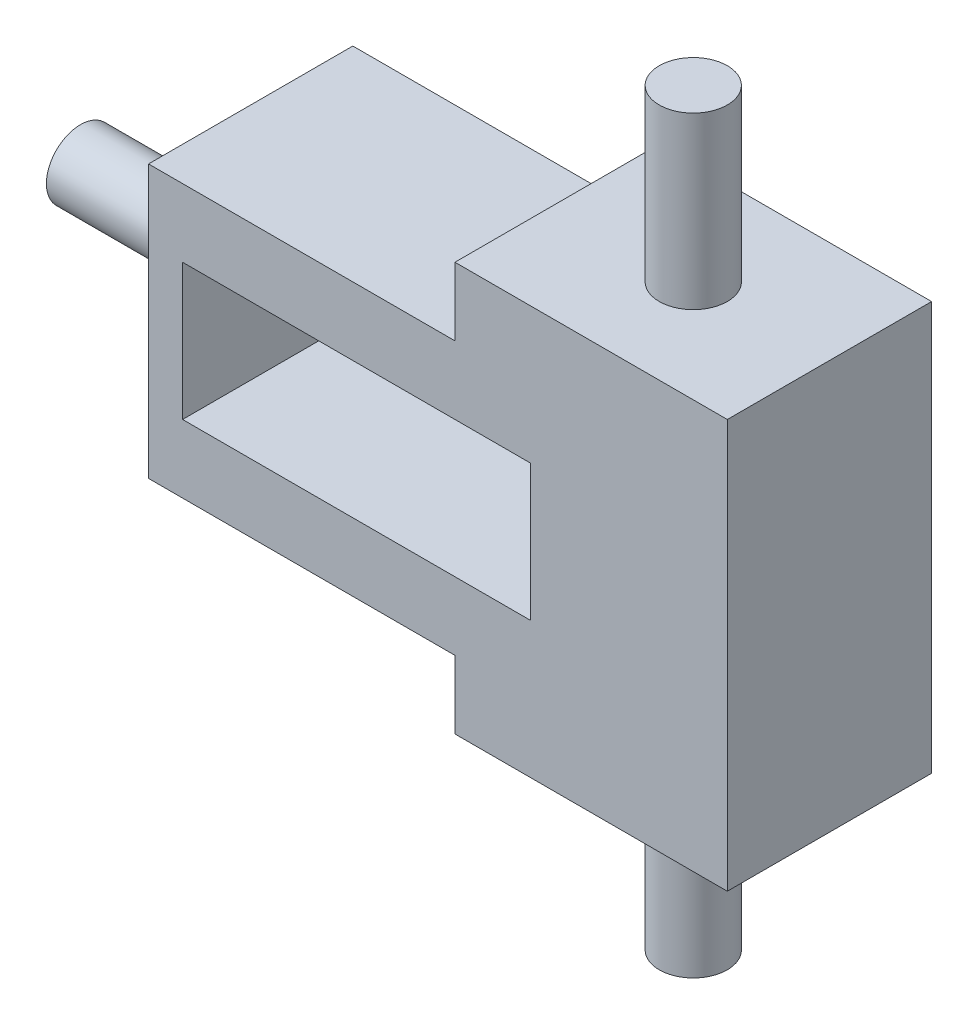
from build123d import *

# Parameters (mm, degrees)
CROQUIS1_W                   = 5.106382979
CROQUIS1_H                   = 2
SALIENTE_EXTRUIR1_DEPTH      = 3
CROQUIS2_R                   = 0.5
SALIENTE_EXTRUIR2_DEPTH      = 2.5
SALIENTE_EXTRUIR2_DEPTH_BACK = 8.5
CROQUIS3_R                   = 0.5
SALIENTE_EXTRUIR3_DEPTH      = 2.5


with BuildPart() as part:
    # Croquis1 → Saliente-Extruir1 (new body)
    with BuildSketch(Plane.XY):
        Polygon((-2, 2), (2, 2), (2, 3), (6, 3), (6, -3), (2, -3), (2, -2), (-2, -2), (-2.5, -2), (-2.5, -0.496453901), (-2.5, 0.503546099), (-2.5, 2), align=None)
        with Locations((0.55319149, 0)):
            Rectangle(CROQUIS1_W, CROQUIS1_H, mode=Mode.SUBTRACT)
    extrude(amount=SALIENTE_EXTRUIR1_DEPTH)

    # Croquis2 → Saliente-Extruir2 (add, two sides)
    with BuildSketch(Plane(origin=(0, 3, 0), x_dir=(1, 0, 0), z_dir=(0, 1, 0))) as saliente_extruir2_sk:
        with Locations((4, -1.5)):
            Circle(CROQUIS2_R)
    extrude(amount=SALIENTE_EXTRUIR2_DEPTH)
    extrude(saliente_extruir2_sk.sketch, amount=-SALIENTE_EXTRUIR2_DEPTH_BACK)

    # Croquis3 → Saliente-Extruir3 (add)
    with BuildSketch(Plane.ZY.offset(2.5)):
        with Locations((1.5, 0)):
            Circle(CROQUIS3_R)
    extrude(amount=SALIENTE_EXTRUIR3_DEPTH)


solid = part.part
